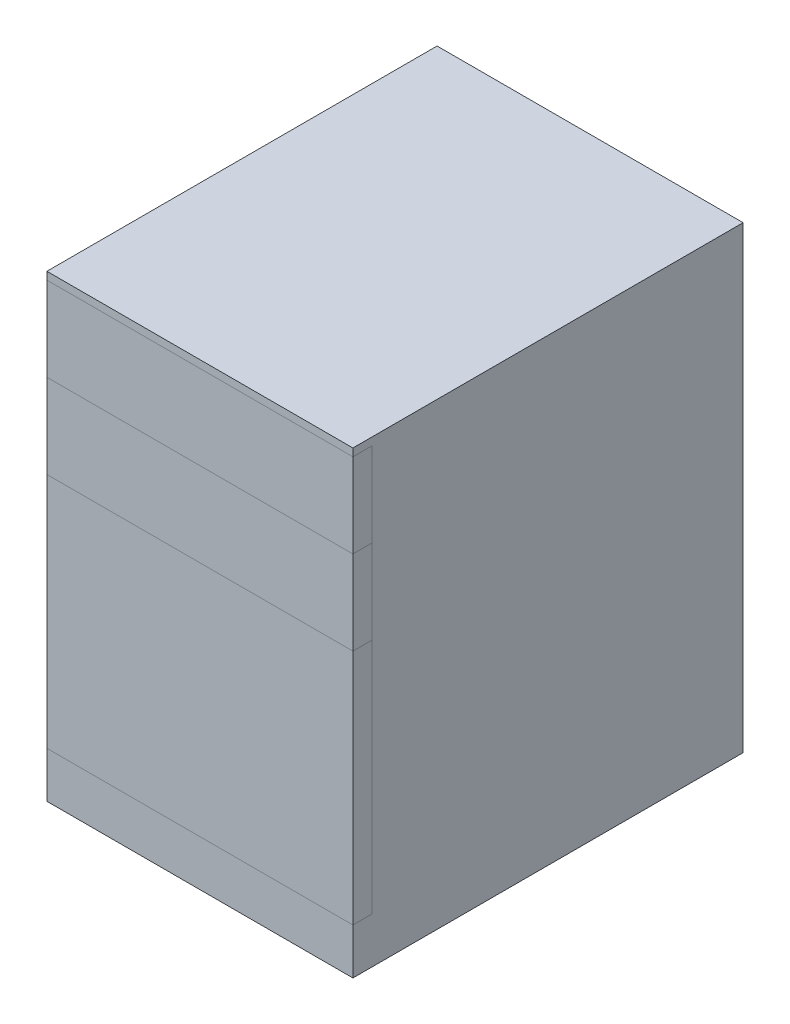
from build123d import *

# Parameters (mm, degrees)
SKETCH1_W           = 400
SKETCH1_H           = 510
BOSS_EXTRUDE1_DEPTH = 600
SKETCH2_W           = 400
SKETCH2_H           = 110
SKETCH2_H_2         = 310
CUT_EXTRUDE1_DEPTH  = 25
BOSS_EXTRUDE3_START = -25
SKETCH2_4_W         = 400
SKETCH2_4_H         = 110
BOSS_EXTRUDE3_DEPTH = 25
BOSS_EXTRUDE4_START = -25
SKETCH2_5_W         = 400
SKETCH2_5_H         = 110
BOSS_EXTRUDE4_DEPTH = 25
BOSS_EXTRUDE5_START = -25
SKETCH2_6_W         = 400
SKETCH2_6_H         = 310
BOSS_EXTRUDE5_DEPTH = 25


with BuildPart() as part:
    # Sketch1 → Boss-Extrude1 (new body)
    with BuildSketch(Plane(origin=(0, 0, 0), x_dir=(1, 0, 0), z_dir=(0, 1, 0))):
        Rectangle(SKETCH1_W, SKETCH1_H)
    extrude(amount=BOSS_EXTRUDE1_DEPTH)

    # Sketch2 → Cut-Extrude1 (cut)
    with BuildSketch(Plane.XY.offset(255)):
        with Locations((0, 425)):
            Rectangle(SKETCH2_W, SKETCH2_H)
        with Locations((0, 535)):
            Rectangle(SKETCH2_W, SKETCH2_H)
        with Locations((0, 215)):
            Rectangle(SKETCH2_W, SKETCH2_H_2)
    extrude(amount=-CUT_EXTRUDE1_DEPTH, mode=Mode.SUBTRACT)


with BuildPart() as body_2:
    # Sketch2_4 → Boss-Extrude3 (new body)
    with BuildSketch(Plane.XY.offset(255).offset(BOSS_EXTRUDE3_START)):
        with Locations((0, 535)):
            Rectangle(SKETCH2_4_W, SKETCH2_4_H)
    extrude(amount=BOSS_EXTRUDE3_DEPTH)


with BuildPart() as body_3:
    # Sketch2_5 → Boss-Extrude4 (new body)
    with BuildSketch(Plane.XY.offset(255).offset(BOSS_EXTRUDE4_START)):
        with Locations((0, 425)):
            Rectangle(SKETCH2_5_W, SKETCH2_5_H)
    extrude(amount=BOSS_EXTRUDE4_DEPTH)


with BuildPart() as body_4:
    # Sketch2_6 → Boss-Extrude5 (new body)
    with BuildSketch(Plane.XY.offset(255).offset(BOSS_EXTRUDE5_START)):
        with Locations((0, 215)):
            Rectangle(SKETCH2_6_W, SKETCH2_6_H)
    extrude(amount=BOSS_EXTRUDE5_DEPTH)


solid = Compound([part.part, body_2.part, body_3.part, body_4.part])
